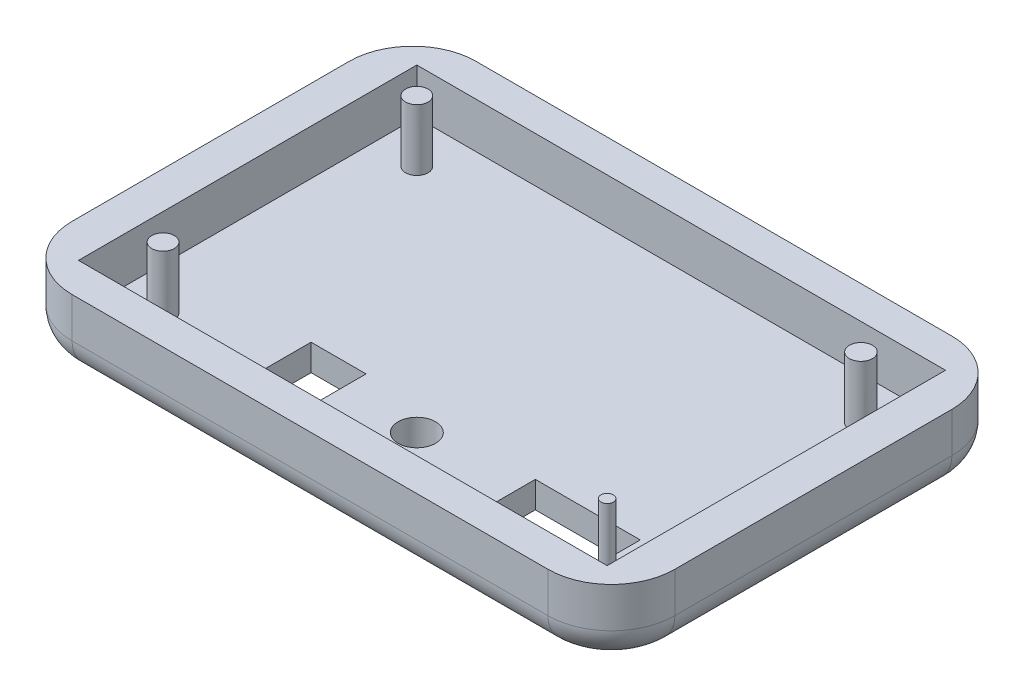
from build123d import *

# Parameters (mm, degrees)
SKETCH1_W           = 72.39
SKETCH1_H           = 48.514
BOSS_EXTRUDE1_DEPTH = 8.636
SKETCH2_W           = 63.5
SKETCH2_H           = 40.64
CUT_EXTRUDE1_DEPTH  = 5.461
FILLET2_R           = 7.62
FILLET3_R           = 3.81
SKETCH4_R           = 2.25
SKETCH4_W           = 12.6
SKETCH4_H           = 5
SKETCH4_W_2         = 6.604
SKETCH4_H_2         = 6.604
CUT_EXTRUDE2_DEPTH  = 7.366
SKETCH5_R           = 1.35
SKETCH5_R_2         = 1.3499973
SKETCH5_R_3         = 1.385
SKETCH5_R_4         = 0.75
BOSS_EXTRUDE2_DEPTH = 7.366


with BuildPart() as part:
    # Sketch1 → Boss-Extrude1 (new body)
    with BuildSketch(Plane(origin=(0, 0, 0), x_dir=(1, 0, 0), z_dir=(0, 1, 0))):
        with Locations((36.195, 24.257)):
            Rectangle(SKETCH1_W, SKETCH1_H)
    extrude(amount=BOSS_EXTRUDE1_DEPTH)

    # Sketch2 → Cut-Extrude1 (cut)
    with BuildSketch(Plane(origin=(0, 8.636, 0), x_dir=(1, 0, 0), z_dir=(0, 1, 0))):
        with Locations((36.195, 24.257)):
            Rectangle(SKETCH2_W, SKETCH2_H)
    extrude(amount=-CUT_EXTRUDE1_DEPTH, mode=Mode.SUBTRACT)

    # Fillet2
    fillet2_edges = [part.edges().sort_by_distance(p)[0] for p in [
        (0, 4.318, -48.514),
        (72.39, 4.318, -48.514),
        (72.39, 4.318, 0),
        (0, 4.318, 0),
    ]]
    fillet(fillet2_edges, radius=FILLET2_R)

    # Fillet3
    fillet3_edges = [part.edges().sort_by_distance(p)[0] for p in [
        (36.195, 0, -48.514),
        (0, 0, -24.257),
        (72.39, 0, -24.257),
        (36.195, 0, 0),
        (2.231846327, 0, -46.282153673),
        (2.231846327, 0, -2.231846327),
        (70.158153673, 0, -2.231846327),
        (70.158153673, 0, -46.282153673),
    ]]
    fillet(fillet3_edges, radius=FILLET3_R)

    # Sketch4 → Cut-Extrude2 (cut)
    with BuildSketch(Plane(origin=(0, 3.175, 0), x_dir=(1, 0, 0), z_dir=(0, 1, 0))):
        with Locations((37.211, 11.811)):
            Circle(SKETCH4_R)
        with Locations((55.499, 11.557)):
            Rectangle(SKETCH4_W, SKETCH4_H)
        with Locations((24.765, 11.557)):
            Rectangle(SKETCH4_W_2, SKETCH4_H_2)
    extrude(amount=-CUT_EXTRUDE2_DEPTH, mode=Mode.SUBTRACT)

    # Sketch5 → Boss-Extrude2 (add)
    with BuildSketch(Plane(origin=(0, 3.175, 0), x_dir=(1, 0, 0), z_dir=(0, 1, 0))):
        with Locations((9.525, 39.497)):
            Circle(SKETCH5_R)
        with Locations((9.525, 9.017)):
            Circle(SKETCH5_R_2)
        with Locations((62.865, 39.497)):
            Circle(SKETCH5_R_3)
        with Locations((62.865, 9.017)):
            Circle(SKETCH5_R_4)
    extrude(amount=BOSS_EXTRUDE2_DEPTH)


solid = part.part
